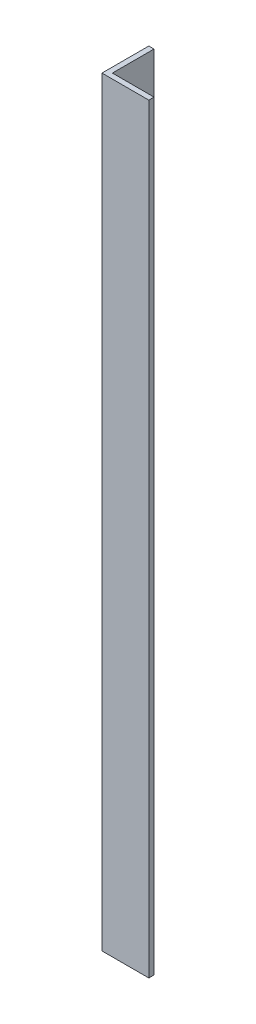
from build123d import *

# Parameters (mm, degrees)
EXTRUDE_1_DEPTH = 730


with BuildPart() as part:
    # Эскиз1 → Вытянуть-Тонкостенный1 (new body)
    with BuildSketch(Plane(origin=(0, 0, 0), x_dir=(1, 0, 0), z_dir=(0, 1, 0))):
        Polygon((0, 45), (0, 0), (45, 0), (45, 5), (5, 5), (5, 45), align=None)
    extrude(amount=EXTRUDE_1_DEPTH)


solid = part.part
